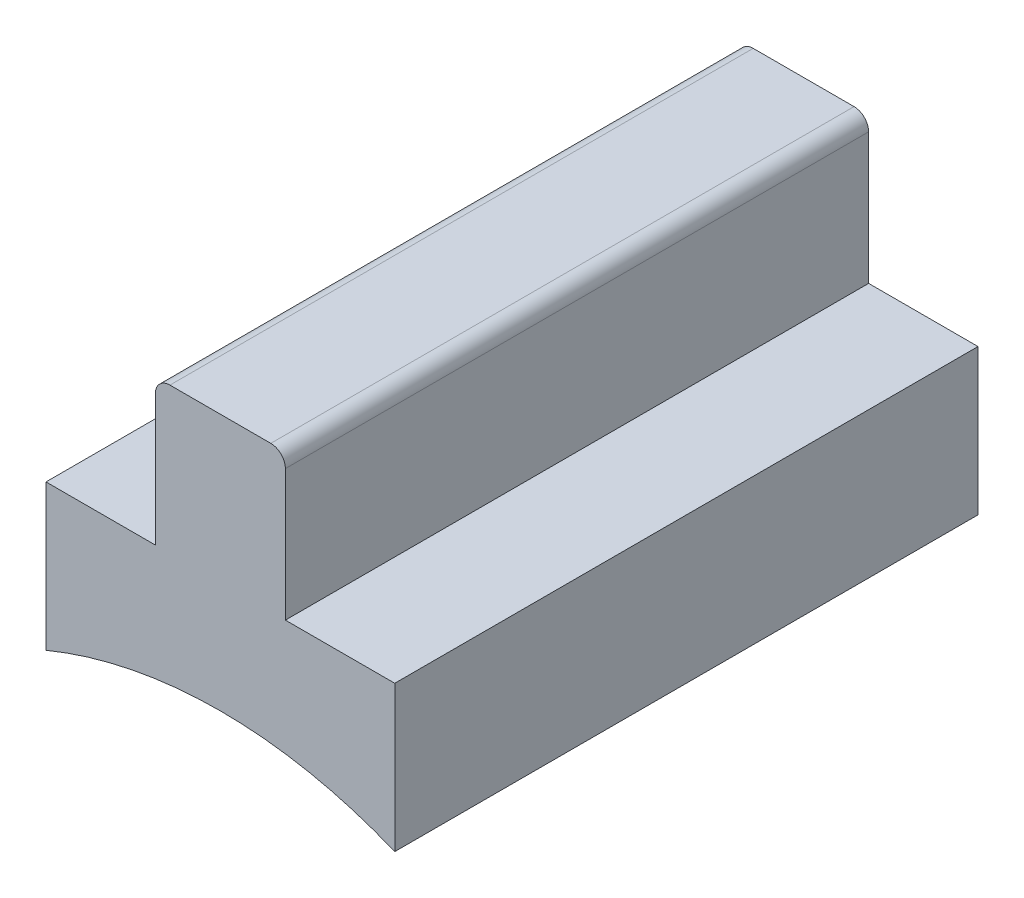
from build123d import *

# Parameters (mm, degrees)
BOSS_EXTRUDE2_DEPTH = 101.6


with BuildPart() as part:
    # Sketch1 → Boss-Extrude2 (new body)
    with BuildSketch(Plane.XY):
        with BuildLine():
            Line((-30.375497444, 98.732937893), (-11.325497444, 98.732937893))
            Line((-11.325497444, 98.732937893), (-11.325497444, 121.592937893))
            ThreePointArc((-11.325497444, 121.592937893), (-10.581548668, 123.388989117), (-8.785497444, 124.132937893))
            Line((-8.785497444, 124.132937893), (8.785497444, 124.132937893))
            ThreePointArc((8.785497444, 124.132937893), (10.581548668, 123.388989117), (11.325497444, 121.592937893))
            Line((11.325497444, 121.592937893), (11.325497444, 98.732937893))
            Line((11.325497444, 98.732937893), (30.375497444, 98.732937893))
            Line((30.375497444, 98.732937893), (30.375497444, 73.332937893))
            ThreePointArc((30.375497444, 73.332937893), (0, 79.375), (-30.375497444, 73.332937893))
            Line((-30.375497444, 73.332937893), (-30.375497444, 98.732937893))
        make_face()
    extrude(amount=BOSS_EXTRUDE2_DEPTH)


solid = part.part
